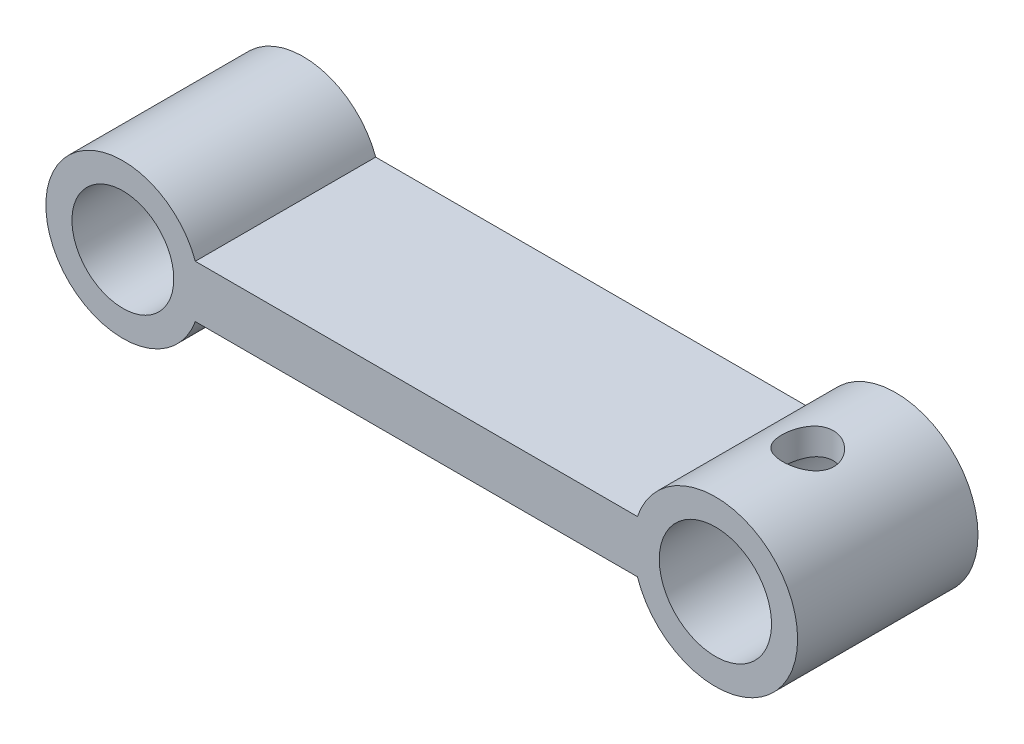
from build123d import *

# Parameters (mm, degrees)
SKETCH1_R         = 1.95
SKETCH1_R_2       = 2.15
MAIN_BODY_DEPTH   = 6.91
SKETCH2_R         = 1
TENDON_HOLE_DEPTH = 7.5


with BuildPart() as part:
    # Sketch1 → main body (new body)
    with BuildSketch(Plane.XY):
        with BuildLine():
            Line((8.468803388, 1), (-8.468803388, 1))
            ThreePointArc((-8.468803388, 1), (-14.194141206, 0), (-8.468803388, -1))
            Line((-8.468803388, -1), (8.468803388, -1))
            ThreePointArc((8.468803388, -1), (14.605858794, 0), (8.468803388, 1))
        make_face()
        with Locations((-11.244141206, 0)):
            Circle(SKETCH1_R, mode=Mode.SUBTRACT)
        with Locations((11.455858794, 0)):
            Circle(SKETCH1_R_2, mode=Mode.SUBTRACT)
    extrude(amount=MAIN_BODY_DEPTH)

    # Sketch2 → tendon hole (cut, symmetric)
    with BuildSketch(Plane(origin=(0, 1, 0), x_dir=(1, 0, 0), z_dir=(0, 1, 0))):
        with Locations((11.537331091, -3.455)):
            Circle(SKETCH2_R)
    extrude(amount=TENDON_HOLE_DEPTH, both=True, mode=Mode.SUBTRACT)


solid = part.part
